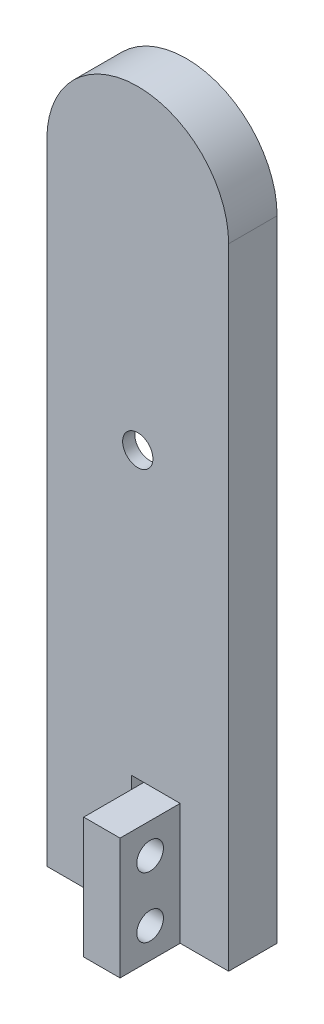
from build123d import *

# Parameters (mm, degrees)
EXTRUDE_1_DEPTH     = 4
CUT_EXTRUDE_1_DEPTH = 3
SKETCH_5_R          = 1.25
CUT_EXTRUDE_2_DEPTH = 12.4
SKETCH_6_W          = 1
SKETCH_6_H          = 10
CUT_EXTRUDE_3_DEPTH = 16.3
SKETCH_9_W          = 5
SKETCH_9_H          = 10
EXTRUDE_4_DEPTH     = 3
SKETCH_10_R         = 1.1
CUT_EXTRUDE_4_DEPTH = 5.1


with BuildPart() as part:
    # 草圖1 → 填料-伸長1 (new body)
    with BuildSketch(Plane.XY):
        with BuildLine():
            Line((7.5, 0), (7.5, 52))
            ThreePointArc((7.5, 52), (0, 59.5), (-7.5, 52))
            Line((-7.5, 52), (-7.5, 0))
            Line((-7.5, 0), (7.5, 0))
        make_face()
    extrude(amount=EXTRUDE_1_DEPTH)

    # 草圖3 → 除料-伸長1 (cut)
    with BuildSketch(Plane.XY):
        with BuildLine():
            ThreePointArc((-2.296635758, 50), (0, 52.296635758), (2.296635758, 50))
            Line((2.296635758, 50), (5, 33.5))
            Line((5, 33.5), (2.272331993, 16.632537074))
            ThreePointArc((2.272331993, 16.632537074), (-0.184323371, 14.705540024), (-2.301851795, 17))
            Line((-2.301851795, 17), (-5, 33.5))
            Line((-5, 33.5), (-2.296635758, 50))
        make_face()
    extrude(amount=CUT_EXTRUDE_1_DEPTH, mode=Mode.SUBTRACT)

    # 草圖5 → 除料-伸長2 (cut)
    with BuildSketch(Plane.XY):
        with Locations((0, 33.5)):
            Circle(SKETCH_5_R)
    extrude(amount=CUT_EXTRUDE_2_DEPTH, mode=Mode.SUBTRACT)

    # 草圖6 → 除料-伸長3 (cut)
    with BuildSketch(Plane.XY):
        with Locations((0, 5)):
            Rectangle(SKETCH_6_W, SKETCH_6_H)
    extrude(amount=CUT_EXTRUDE_3_DEPTH, mode=Mode.SUBTRACT)

    # 草圖9 → 填料-伸長4 (add)
    with BuildSketch(Plane(origin=(0.5, 0, 0), x_dir=(0, 0, -1), z_dir=(1, 0, 0))):
        with Locations((-6.46178466, 5)):
            Rectangle(SKETCH_9_W, SKETCH_9_H)
    extrude(amount=EXTRUDE_4_DEPTH)

    # 草圖10 → 除料-伸長4 (cut)
    with BuildSketch(Plane(origin=(0.5, 0, 0), x_dir=(0, 0, -1), z_dir=(1, 0, 0))):
        with Locations((-6.48089233, 7.5)):
            Circle(SKETCH_10_R)
        with Locations((-6.48089233, 2.5)):
            Circle(SKETCH_10_R)
    extrude(amount=CUT_EXTRUDE_4_DEPTH, mode=Mode.SUBTRACT)


solid = part.part
